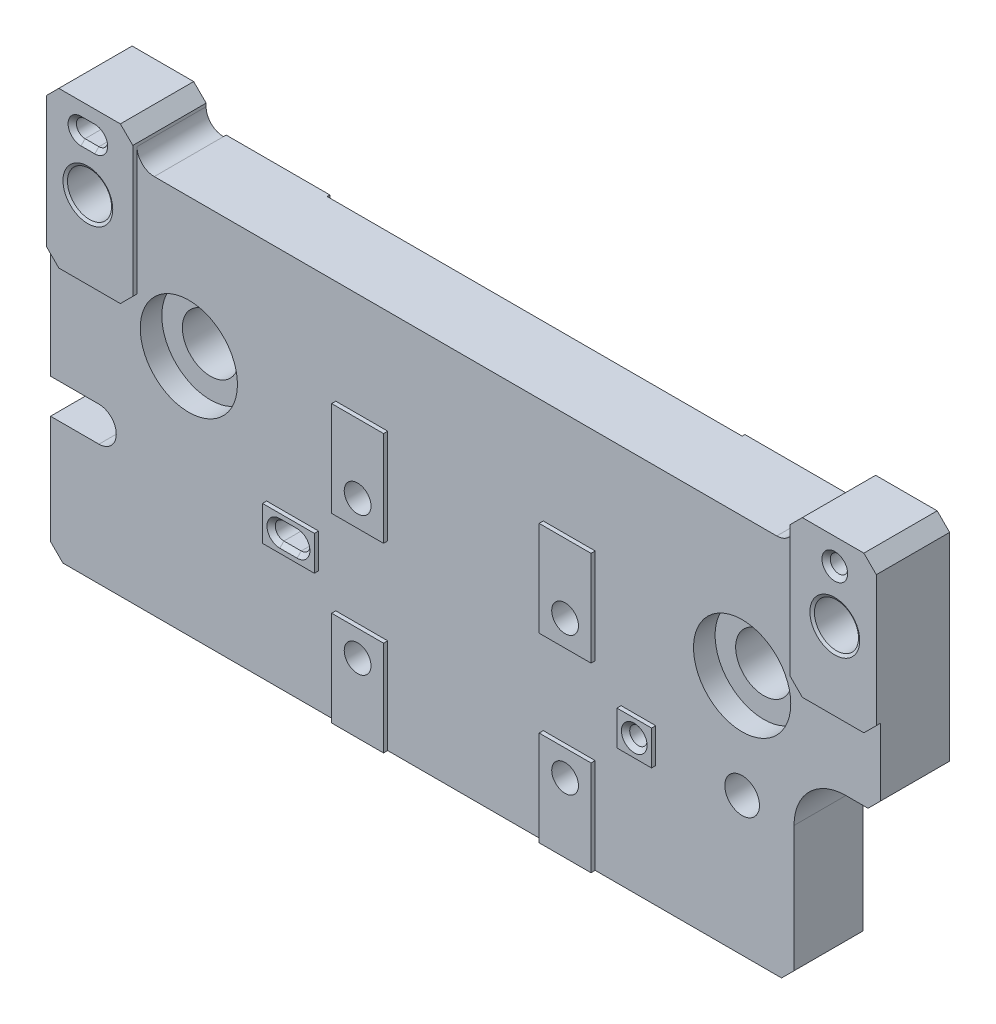
from build123d import *

# Parameters (mm, degrees)
SKETCH1_W                                        = 152.4
SKETCH1_H                                        = 69.85
BASE_EXTRUDE_DEPTH                               = 12.7
SKETCH29_W                                       = 19.05
SKETCH29_H                                       = 17.78
MOUNTING_SURFACES_STAGE2_DEPTH                   = 1.27
CHAMFER1_SIZE                                    = 2.286
SKETCH17_W                                       = 9.525
SKETCH17_H                                       = 17.4625
MOUNTING_SURFACES_MAGNET_BRACKET_DEPTH           = 0.762
EXTRUDE1_DEPTH                                   = 13.462
SKETCH18_R                                       = 1.59512
PIN_HOLES_SLOTS_MAGNET_BLOCK_BOBIN_DEPTH         = 1.762
PIN_HOLES_SLOTS_MAGNET_BLOCK_BOBIN_DEPTH_BACK    = 6.35
SKETCH19_W                                       = 6.35
SKETCH19_H                                       = 6.35
SKETCH19_R                                       = 1.59512
SKETCH19_W_2                                     = 9.525
PIN_HOLE_SLOT_MAGNET_BLOCK_SURFACE_DEPTH         = 0.762
CLEARANCE_CUT_GS_13_SCREW_HEAD_DEPTH             = 1.762
CLEARANCE_CUT_GS_13_SCREW_HEAD_DEPTH_BACK        = 14.97
CBORE_FOR_8_SOCKET_HEAD_CAP_SCREW1_D             = 4.9149
CBORE_FOR_8_SOCKET_HEAD_CAP_SCREW1_CBORE_D       = 8.89
CBORE_FOR_8_SOCKET_HEAD_CAP_SCREW1_CBORE_DEPTH   = 7.62
TAPPED_HOLE_FOR_1_4_20_HELICOIL1_AT_2_COUNT      = 2
TAPPED_HOLE_FOR_1_4_20_HELICOIL1_AT_2_PITCH      = 137.16
SKETCH28_R                                       = 3.18389
PIN_HOLE_SLOT_TO_STAGE2_DEPTH                    = 15.732
CBORE_FOR_3_8_SOCKET_HEAD_CAP_SCREW1_D           = 10.3124
CBORE_FOR_3_8_SOCKET_HEAD_CAP_SCREW1_CBORE_D     = 17.8562
CBORE_FOR_3_8_SOCKET_HEAD_CAP_SCREW1_CBORE_DEPTH = 3.9624
CHAMFER3_SIZE                                    = 0.762
F_3_32_0_09375_DIAMETER_HOLE1_D                  = 2.38125
CHAMFER4_SIZE                                    = 1.524
SKETCH37_W                                       = 15.875
SKETCH37_H                                       = 6.0325
EXTRUDE2_DEPTH                                   = 0.762
FILLET1_R                                        = 3.175
CHAMFER7_SIZE                                    = 0.762
CHAMFER8_SIZE                                    = 2.286


with BuildPart() as part:
    # Sketch1 → Base Extrude (new body)
    with BuildSketch(Plane.XY):
        with Locations((0, 9.525)):
            Rectangle(SKETCH1_W, SKETCH1_H)
    extrude(amount=BASE_EXTRUDE_DEPTH)

    # Sketch29 → Mounting Surfaces_ Stage2 (add)
    with BuildSketch(Plane(origin=(0, 0, 0), x_dir=(-1, 0, 0), z_dir=(0, 0, -1))):
        with Locations((-47.625, 35.56)):
            Rectangle(SKETCH29_W, SKETCH29_H)
        with Locations((-47.625, -16.51)):
            Rectangle(SKETCH29_W, SKETCH29_H)
        with Locations((47.625, 35.56)):
            Rectangle(SKETCH29_W, SKETCH29_H)
        with Locations((47.625, -16.51)):
            Rectangle(SKETCH29_W, SKETCH29_H)
    extrude(amount=MOUNTING_SURFACES_STAGE2_DEPTH)

    # Chamfer1
    chamfer1_edges = [part.edges().sort_by_distance(p)[0] for p in [
        (-76.2, 44.45, 6.35),
        (76.2, 44.45, 6.35),
        (76.2, -25.4, 6.35),
        (-76.2, -25.4, 6.35),
    ]]
    chamfer(chamfer1_edges, length=CHAMFER1_SIZE)

    # Sketch17 → Mounting Surfaces_ Magnet _ Bracket (add)
    with BuildSketch(Plane.XY.offset(12.7)):
        with Locations((-19.05, 16.66875)):
            Rectangle(SKETCH17_W, SKETCH17_H)
        with Locations((19.05, 16.66875)):
            Rectangle(SKETCH17_W, SKETCH17_H)
        with Locations((19.05, -16.66875)):
            Rectangle(SKETCH17_W, SKETCH17_H)
        with Locations((-19.05, -16.66875)):
            Rectangle(SKETCH17_W, SKETCH17_H)
        Polygon((-73.914, 44.45), (-76.2, 42.164), (-76.2, 27.94), (-60.325, 27.94), (-60.325, 44.45), align=None)
        Polygon((73.914, 44.45), (60.325, 44.45), (60.325, 27.94), (76.2, 27.94), (76.2, 42.164), align=None)
    extrude(amount=MOUNTING_SURFACES_MAGNET_BRACKET_DEPTH)

    # Sketch36 → Extrude1 (add)
    with BuildSketch(Plane.XY.offset(13.462)):
        Polygon((-76.2, 42.164), (-76.2, 48.1965), (-73.914, 50.4825), (-60.325, 50.4825), (-60.325, 44.45), (-73.914, 44.45), align=None)
        Polygon((60.325, 44.45), (60.325, 50.4825), (73.914, 50.4825), (76.2, 48.1965), (76.2, 42.164), (73.914, 44.45), align=None)
    extrude(amount=-EXTRUDE1_DEPTH)

    # Sketch18 → Pin holes _ Slots_ Magnet Block _ Bobin (cut, two sides)
    with BuildSketch(Plane.XY.offset(12.7)) as pin_holes_slots_magnet_block_bobin_sk:
        with Locations((31.75, 0)):
            Circle(SKETCH18_R)
        with Locations((68.58, 45.72)):
            Circle(SKETCH18_R)
        with BuildLine():
            Line((-33.3375, 1.59512), (-30.1625, 1.59512))
            ThreePointArc((-30.1625, 1.59512), (-28.56738, 0), (-30.1625, -1.59512))
            Line((-30.1625, -1.59512), (-33.3375, -1.59512))
            ThreePointArc((-33.3375, -1.59512), (-34.93262, 0), (-33.3375, 1.59512))
        make_face()
        with BuildLine():
            Line((-69.85, 47.31512), (-67.31, 47.31512))
            ThreePointArc((-67.31, 47.31512), (-65.71488, 45.72), (-67.31, 44.12488))
            Line((-67.31, 44.12488), (-69.85, 44.12488))
            ThreePointArc((-69.85, 44.12488), (-71.44512, 45.72), (-69.85, 47.31512))
        make_face()
    extrude(amount=PIN_HOLES_SLOTS_MAGNET_BLOCK_BOBIN_DEPTH, mode=Mode.SUBTRACT)
    extrude(pin_holes_slots_magnet_block_bobin_sk.sketch, amount=-PIN_HOLES_SLOTS_MAGNET_BLOCK_BOBIN_DEPTH_BACK, mode=Mode.SUBTRACT)

    # Sketch19 → Pin hole _ Slot_ Magnet Block surface (add)
    with BuildSketch(Plane.XY.offset(12.7)):
        with Locations((31.75, 0)):
            Rectangle(SKETCH19_W, SKETCH19_H)
        with Locations((31.75, 0)):
            Circle(SKETCH19_R, mode=Mode.SUBTRACT)
        with Locations((-31.75, 0)):
            Rectangle(SKETCH19_W_2, SKETCH19_H)
        with BuildLine():
            Line((-30.1625, 1.59512), (-33.3375, 1.59512))
            ThreePointArc((-33.3375, 1.59512), (-34.93262, 0), (-33.3375, -1.59512))
            Line((-33.3375, -1.59512), (-30.1625, -1.59512))
            ThreePointArc((-30.1625, -1.59512), (-28.56738, 0), (-30.1625, 1.59512))
        make_face(mode=Mode.SUBTRACT)
    extrude(amount=PIN_HOLE_SLOT_MAGNET_BLOCK_SURFACE_DEPTH)

    # Sketch20 → Clearance Cut_ GS-13 Screw Head (cut, two sides)
    with BuildSketch(Plane.XY.offset(12.7)) as clearance_cut_gs_13_screw_head_sk:
        with BuildLine():
            Line((60.325, 0), (60.325, -25.4))
            Line((60.325, -25.4), (73.914, -25.4))
            Line((73.914, -25.4), (76.2, -23.114))
            Line((76.2, -23.114), (76.2, 9.525))
            Line((76.2, 9.525), (69.85, 9.525))
            ThreePointArc((69.85, 9.525), (63.114807909, 6.735192091), (60.325, 0))
        make_face()
    extrude(amount=CLEARANCE_CUT_GS_13_SCREW_HEAD_DEPTH, mode=Mode.SUBTRACT)
    extrude(clearance_cut_gs_13_screw_head_sk.sketch, amount=-CLEARANCE_CUT_GS_13_SCREW_HEAD_DEPTH_BACK, mode=Mode.SUBTRACT)

    # CBORE for _8 Socket Head Cap Screw1 (through all)
    with Locations(Plane(origin=(0, 0, 0), x_dir=(-1, 0, 0), z_dir=(0, 0, -1))):
        with Locations((-19.05, 12.7), (19.05, 12.7), (19.05, -12.7), (-19.05, -12.7)):
            CounterBoreHole(CBORE_FOR_8_SOCKET_HEAD_CAP_SCREW1_D / 2, CBORE_FOR_8_SOCKET_HEAD_CAP_SCREW1_CBORE_D / 2, CBORE_FOR_8_SOCKET_HEAD_CAP_SCREW1_CBORE_DEPTH)

    # Sketch25 → Tapped Hole for 1_4-20 Helicoil1 (revolve, cut)
    with BuildSketch(Plane(origin=(68.58, 36.195, 13.462), x_dir=(0, -1, 0), z_dir=(1, 0, 0))):
        Polygon((0, 0), (0, 14.732025), (3.3782, 14.732025), (3.3782, 11.6586), (4.04749, 11.6586), (4.04749, 0.30282599), (4.572, 0), align=None)
    tapped_hole_for_1_4_20_helicoil1 = revolve(axis=Axis((68.58, 36.195, 19.812), (0, 0, -1)), mode=Mode.SUBTRACT)

    # Tapped Hole for 1_4-20 Helicoil1 at 2: Tapped Hole for 1_4-20 Helicoil1 ×2
    with Locations(*[(-i * TAPPED_HOLE_FOR_1_4_20_HELICOIL1_AT_2_PITCH, 0, 0) for i in range(1, TAPPED_HOLE_FOR_1_4_20_HELICOIL1_AT_2_COUNT)]):
        add(tapped_hole_for_1_4_20_helicoil1, mode=Mode.SUBTRACT)

    # Sketch28 → Pin Hole _ Slot to Stage2 (cut, through all)
    with BuildSketch(Plane(origin=(0, 0, -1.27), x_dir=(-1, 0, 0), z_dir=(0, 0, -1))):
        with Locations(Location((-50.8, 0, 0), (0, 0, 180))):  # turned: the seam where the file's is
            Circle(SKETCH28_R)
        with BuildLine():
            Line((67.31, 3.18389), (80.01, 3.18389))
            ThreePointArc((80.01, 3.18389), (83.19389, 0), (80.01, -3.18389))
            Line((80.01, -3.18389), (67.31, -3.18389))
            ThreePointArc((67.31, -3.18389), (64.12611, 0), (67.31, 3.18389))
        make_face()
    extrude(amount=-PIN_HOLE_SLOT_TO_STAGE2_DEPTH, mode=Mode.SUBTRACT)

    # CBORE for 3_8 Socket Head Cap Screw1 (through all)
    with Locations(Plane.XY.offset(12.7)):
        with Locations((-50.8, 19.05), (50.8, 19.05)):
            CounterBoreHole(CBORE_FOR_3_8_SOCKET_HEAD_CAP_SCREW1_D / 2, CBORE_FOR_3_8_SOCKET_HEAD_CAP_SCREW1_CBORE_D / 2, CBORE_FOR_3_8_SOCKET_HEAD_CAP_SCREW1_CBORE_DEPTH)

    # Chamfer3
    chamfer3_edges = [part.edges().sort_by_distance(p)[0] for p in [
        (66.98488, 45.72, 13.462),
        (-71.44512, 45.72, 13.462),
        (-68.58, 44.12488, 13.462),
        (-65.71488, 45.72, 13.462),
        (-68.58, 47.31512, 13.462),
        (30.15488, 0, 13.462),
        (-31.75, 1.59512, 13.462),
        (-28.56738, 0, 13.462),
        (-31.75, -1.59512, 13.462),
        (-34.93262, 0, 13.462),
    ]]
    chamfer(chamfer3_edges, length=CHAMFER3_SIZE)

    # 3_32 _0.09375_ Diameter Hole1 (through all)
    with Locations(Plane(origin=(0, 0, -1.27), x_dir=(-1, 0, 0), z_dir=(0, 0, -1))):
        with Locations((68.58, 45.72), (-68.58, 45.72), (-31.75, 0), (31.75, 0)):
            Hole(F_3_32_0_09375_DIAMETER_HOLE1_D / 2)

    # Chamfer4
    chamfer4_edges = [part.edges().sort_by_distance(p)[0] for p in [
        (47.61611, 0, 0),
        (-64.12611, 0, 0),
        (-71.755, 3.18389, 0),
        (-71.755, -3.18389, 0),
    ]]
    chamfer(chamfer4_edges, length=CHAMFER4_SIZE)

    # Sketch37 → Extrude2 (add)
    with BuildSketch(Plane.XY.offset(13.462)):
        with Locations((-68.2625, 24.92375)):
            Rectangle(SKETCH37_W, SKETCH37_H)
        with Locations((68.2625, 24.92375)):
            Rectangle(SKETCH37_W, SKETCH37_H)
    extrude(amount=-EXTRUDE2_DEPTH)

    # Fillet1
    fillet1_edges = [part.edges().sort_by_distance(p)[0] for p in [
        (60.325, 44.45, 6.35),
        (-60.325, 44.45, 6.35),
    ]]
    fillet(fillet1_edges, radius=FILLET1_R)

    # Chamfer7
    chamfer7_edges = [part.edges().sort_by_distance(p)[0] for p in [
        (-47.625, 44.45, -1.27),
        (-57.15, 35.56, -1.27),
        (-47.625, 26.67, -1.27),
        (-38.1, 35.56, -1.27),
        (47.625, 44.45, -1.27),
        (38.1, 35.56, -1.27),
        (47.625, 26.67, -1.27),
        (57.15, 35.56, -1.27),
        (47.625, -25.4, -1.27),
        (57.15, -16.51, -1.27),
        (47.625, -7.62, -1.27),
        (38.1, -16.51, -1.27),
        (-47.625, -25.4, -1.27),
        (-38.1, -16.51, -1.27),
        (-47.625, -7.62, -1.27),
        (-57.15, -16.51, -1.27),
    ]]
    chamfer(chamfer7_edges, length=CHAMFER7_SIZE)

    # Chamfer8
    chamfer8_edges = [part.edges().sort_by_distance(p)[0] for p in [
        (-60.325, 50.4825, 6.731),
        (60.325, 50.4825, 6.731),
        (60.325, -25.4, 6.35),
        (76.2, 9.525, 6.35),
        (-76.2, 21.9075, 13.081),
        (-60.325, 21.9075, 13.081),
        (60.325, 21.9075, 13.081),
        (76.2, 21.9075, 13.081),
    ]]
    chamfer(chamfer8_edges, length=CHAMFER8_SIZE)


solid = part.part
